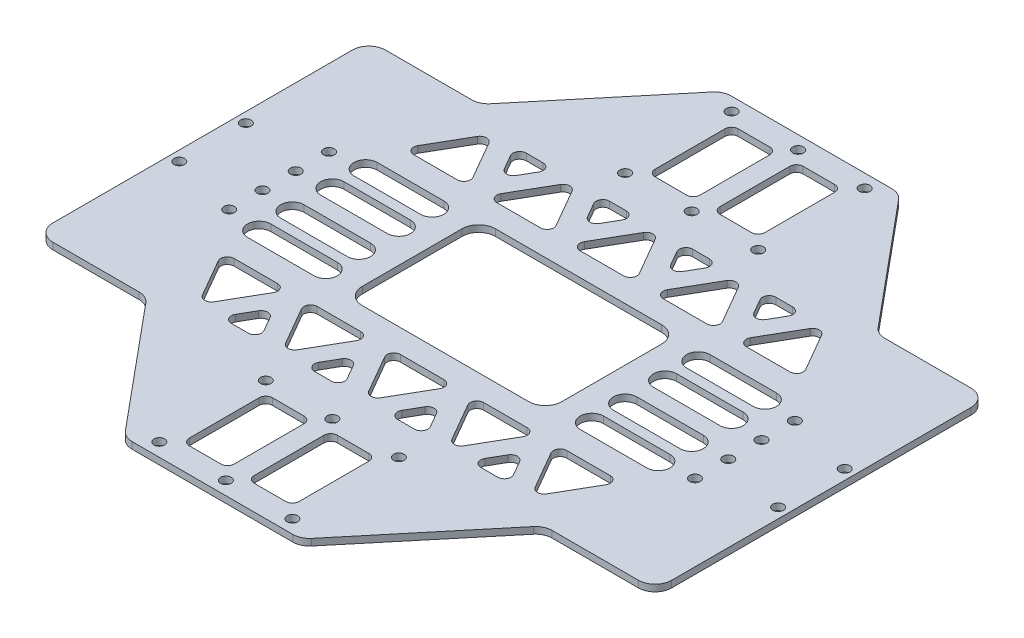
from build123d import *

# Parameters (mm, degrees)
SKETCH_1_W          = 186
SKETCH_1_H          = 100
SKETCH_1_R          = 1.6
EXTRUDE_1_DEPTH     = 2
SKETCH_2_W          = 53
SKETCH_2_H          = 40
SKETCH_2_R          = 1.6
EXTRUDE_2_DEPTH     = 2
SKETCH_3_R          = 1.6
CUT_EXTRUDE_1_DEPTH = 3
EXTRUDE_3_DEPTH     = 2
SKETCH_5_W          = 13.5
SKETCH_5_H          = 25
SKETCH_5_W_2        = 60
SKETCH_5_H_2        = 40
CUT_EXTRUDE_2_DEPTH = 3
FILLET_1_R          = 2
FILLET_2_R          = 5


with BuildPart() as part:
    # 草图1 → 凸台-拉伸1 (new body)
    with BuildSketch(Plane(origin=(0, 0, 0), x_dir=(1, 0, 0), z_dir=(0, 1, 0))):
        Rectangle(SKETCH_1_W, SKETCH_1_H)
        with Locations((-90, 10)):
            Circle(SKETCH_1_R, mode=Mode.SUBTRACT)
        with Locations((-90, -10)):
            Circle(SKETCH_1_R, mode=Mode.SUBTRACT)
        with Locations((90, -10)):
            Circle(SKETCH_1_R, mode=Mode.SUBTRACT)
        with Locations((90, 10)):
            Circle(SKETCH_1_R, mode=Mode.SUBTRACT)
    extrude(amount=EXTRUDE_1_DEPTH)

    # 草图2 → 凸台-拉伸2 (add)
    with BuildSketch(Plane.XZ):
        with Locations((0, 70)):
            Rectangle(SKETCH_2_W, SKETCH_2_H)
        with Locations((-20, 86)):
            Circle(SKETCH_2_R, mode=Mode.SUBTRACT)
        with Locations((0, 86)):
            Circle(SKETCH_2_R, mode=Mode.SUBTRACT)
        with Locations((20, 86)):
            Circle(SKETCH_2_R, mode=Mode.SUBTRACT)
        with Locations((20, 54)):
            Circle(SKETCH_2_R, mode=Mode.SUBTRACT)
        with Locations((0, 54)):
            Circle(SKETCH_2_R, mode=Mode.SUBTRACT)
        with Locations((-20, 54)):
            Circle(SKETCH_2_R, mode=Mode.SUBTRACT)
        with Locations((0, -70)):
            Rectangle(SKETCH_2_W, SKETCH_2_H)
        with Locations((-20, -54)):
            Circle(SKETCH_2_R, mode=Mode.SUBTRACT)
        with Locations((0, -54)):
            Circle(SKETCH_2_R, mode=Mode.SUBTRACT)
        with Locations((20, -54)):
            Circle(SKETCH_2_R, mode=Mode.SUBTRACT)
        with Locations((20, -86)):
            Circle(SKETCH_2_R, mode=Mode.SUBTRACT)
        with Locations((0, -86)):
            Circle(SKETCH_2_R, mode=Mode.SUBTRACT)
        with Locations((-20, -86)):
            Circle(SKETCH_2_R, mode=Mode.SUBTRACT)
    extrude(amount=-EXTRUDE_2_DEPTH)

    # 草图3 → 切除-拉伸1 (cut, through all)
    with BuildSketch(Plane(origin=(0, 2, 0), x_dir=(1, 0, 0), z_dir=(0, 1, 0))):
        with Locations((-70, -15)):
            Circle(SKETCH_3_R)
        with Locations((-70, -5)):
            Circle(SKETCH_3_R)
        with Locations((-70, 5)):
            Circle(SKETCH_3_R)
        with Locations((-70, 15)):
            Circle(SKETCH_3_R)
        with Locations((70, 15)):
            Circle(SKETCH_3_R)
        with Locations((70, 5)):
            Circle(SKETCH_3_R)
        with Locations((70, -5)):
            Circle(SKETCH_3_R)
        with Locations((70, -15)):
            Circle(SKETCH_3_R)
    extrude(amount=-CUT_EXTRUDE_1_DEPTH, mode=Mode.SUBTRACT)

    # 草图4 → 凸台-拉伸3 (add)
    with BuildSketch(Plane(origin=(0, 2, 0), x_dir=(1, 0, 0), z_dir=(0, 1, 0))):
        Polygon((-26.5, 90), (-59.75, 50), (-26.5, 50), align=None)
        Polygon((59.75, 50), (26.5, 50), (26.5, 90), align=None)
        Polygon((26.5, -90), (59.75, -50), (26.5, -50), align=None)
        Polygon((-59.75, -50), (-26.5, -50), (-26.5, -90), align=None)
    extrude(amount=-EXTRUDE_3_DEPTH)

    # 草图5 → 切除-拉伸2 (cut, through all)
    with BuildSketch(Plane.XZ):
        with Locations((9.75, 70)):
            Rectangle(SKETCH_5_W, SKETCH_5_H)
        with Locations((-9.75, 70)):
            Rectangle(SKETCH_5_W, SKETCH_5_H)
        with Locations((9.75, -70)):
            Rectangle(SKETCH_5_W, SKETCH_5_H)
        with Locations((-9.75, -70)):
            Rectangle(SKETCH_5_W, SKETCH_5_H)
        with BuildLine():
            Line((-60, -2.5), (-40, -2.5))
            ThreePointArc((-40, -2.5), (-36.5, -6), (-40, -9.5))
            Line((-40, -9.5), (-60, -9.5))
            ThreePointArc((-60, -9.5), (-63.5, -6), (-60, -2.5))
        make_face()
        Rectangle(SKETCH_5_W_2, SKETCH_5_H_2)
        with BuildLine():
            Line((-60, -19.5), (-40, -19.5))
            ThreePointArc((-40, -19.5), (-36.5, -16), (-40, -12.5))
            Line((-40, -12.5), (-60, -12.5))
            ThreePointArc((-60, -12.5), (-63.5, -16), (-60, -19.5))
        make_face()
        with BuildLine():
            Line((-60, 12.5), (-40, 12.5))
            ThreePointArc((-40, 12.5), (-36.5, 16), (-40, 19.5))
            Line((-40, 19.5), (-60, 19.5))
            ThreePointArc((-60, 19.5), (-63.5, 16), (-60, 12.5))
        make_face()
        with BuildLine():
            Line((-60, 2.5), (-40, 2.5))
            ThreePointArc((-40, 2.5), (-36.5, 6), (-40, 9.5))
            Line((-40, 9.5), (-60, 9.5))
            ThreePointArc((-60, 9.5), (-63.5, 6), (-60, 2.5))
        make_face()
        with BuildLine():
            Line((60, 2.5), (40, 2.5))
            ThreePointArc((40, 2.5), (36.5, 6), (40, 9.5))
            Line((40, 9.5), (60, 9.5))
            ThreePointArc((60, 9.5), (63.5, 6), (60, 2.5))
        make_face()
        with BuildLine():
            Line((60, 12.5), (40, 12.5))
            ThreePointArc((40, 12.5), (36.5, 16), (40, 19.5))
            Line((40, 19.5), (60, 19.5))
            ThreePointArc((60, 19.5), (63.5, 16), (60, 12.5))
        make_face()
        with BuildLine():
            Line((60, -12.5), (40, -12.5))
            ThreePointArc((40, -12.5), (36.5, -16), (40, -19.5))
            Line((40, -19.5), (60, -19.5))
            ThreePointArc((60, -19.5), (63.5, -16), (60, -12.5))
        make_face()
        with BuildLine():
            Line((60, -2.5), (40, -2.5))
            ThreePointArc((40, -2.5), (36.5, -6), (40, -9.5))
            Line((40, -9.5), (60, -9.5))
            ThreePointArc((60, -9.5), (63.5, -6), (60, -2.5))
        make_face()
        Polygon((-50, 44.320508076), (-60, 27), (-40, 27), align=None)
        Polygon((-15, 27), (-25, 44.320508076), (-35, 27), align=None)
        Polygon((10, 27), (0, 44.320508076), (-10, 27), align=None)
        Polygon((35, 27), (25, 44.320508076), (15, 27), align=None)
        Polygon((60, 27), (50, 44.320508076), (40, 27), align=None)
        Polygon((-43.5, 44.320508076), (-31.5, 44.320508076), (-37.5, 33.92820323), align=None)
        Polygon((-12.5, 33.92820323), (-18.5, 44.320508076), (-6.5, 44.320508076), align=None)
        Polygon((12.5, 33.92820323), (6.5, 44.320508076), (18.5, 44.320508076), align=None)
        Polygon((37.5, 33.92820323), (31.5, 44.320508076), (43.5, 44.320508076), align=None)
        Polygon((43.5, -44.320508076), (37.5, -33.92820323), (31.5, -44.320508076), align=None)
        Polygon((18.5, -44.320508076), (12.5, -33.92820323), (6.5, -44.320508076), align=None)
        Polygon((-6.5, -44.320508076), (-12.5, -33.92820323), (-18.5, -44.320508076), align=None)
        Polygon((-37.5, -33.92820323), (-43.5, -44.320508076), (-31.5, -44.320508076), align=None)
        Polygon((40, -27), (60, -27), (50, -44.320508076), align=None)
        Polygon((15, -27), (35, -27), (25, -44.320508076), align=None)
        Polygon((-10, -27), (10, -27), (0, -44.320508076), align=None)
        Polygon((-35, -27), (-15, -27), (-25, -44.320508076), align=None)
        Polygon((-40, -27), (-50, -44.320508076), (-60, -27), align=None)
    extrude(amount=-CUT_EXTRUDE_2_DEPTH, mode=Mode.SUBTRACT)

    # 圆角1
    fillet_1_edges = [part.edges().sort_by_distance(p)[0] for p in [
        (-37.5, 1, 33.92820323),
        (-43.5, 1, 44.320508076),
        (-31.5, 1, 44.320508076),
        (-50, 1, 44.320508076),
        (-40, 1, 27),
        (-60, 1, 27),
        (-35, 1, 27),
        (-25, 1, 44.320508076),
        (-15, 1, 27),
        (-10, 1, 27),
        (0, 1, 44.320508076),
        (10, 1, 27),
        (16.5, 1, 82.5),
        (16.5, 1, 57.5),
        (3, 1, 57.5),
        (3, 1, 82.5),
        (16.5, 1, -82.5),
        (3, 1, -82.5),
        (3, 1, -57.5),
        (16.5, 1, -57.5),
        (-16.5, 1, -82.5),
        (-16.5, 1, -57.5),
        (-3, 1, -57.5),
        (-3, 1, -82.5),
        (50, 1, -44.320508076),
        (40, 1, -27),
        (60, 1, -27),
        (18.5, 1, -44.320508076),
        (6.5, 1, -44.320508076),
        (12.5, 1, -33.92820323),
        (43.5, 1, -44.320508076),
        (31.5, 1, -44.320508076),
        (37.5, 1, -33.92820323),
        (-15, 1, -27),
        (-25, 1, -44.320508076),
        (-35, 1, -27),
        (25, 1, -44.320508076),
        (15, 1, -27),
        (35, 1, -27),
        (0, 1, -44.320508076),
        (-10, 1, -27),
        (10, 1, -27),
        (6.5, 1, 44.320508076),
        (18.5, 1, 44.320508076),
        (12.5, 1, 33.92820323),
        (-18.5, 1, 44.320508076),
        (-6.5, 1, 44.320508076),
        (-12.5, 1, 33.92820323),
        (40, 1, 27),
        (50, 1, 44.320508076),
        (60, 1, 27),
        (15, 1, 27),
        (25, 1, 44.320508076),
        (35, 1, 27),
        (-50, 1, -44.320508076),
        (-60, 1, -27),
        (-40, 1, -27),
        (-18.5, 1, -44.320508076),
        (-12.5, 1, -33.92820323),
        (-6.5, 1, -44.320508076),
        (-37.5, 1, -33.92820323),
        (-31.5, 1, -44.320508076),
        (-43.5, 1, -44.320508076),
        (31.5, 1, 44.320508076),
        (43.5, 1, 44.320508076),
        (37.5, 1, 33.92820323),
        (-16.5, 1, 57.5),
        (-16.5, 1, 82.5),
        (-3, 1, 82.5),
        (-3, 1, 57.5),
    ]]
    fillet(fillet_1_edges, radius=FILLET_1_R)

    # 圆角2
    fillet_2_edges = [part.edges().sort_by_distance(p)[0] for p in [
        (-59.75, 1, -50),
        (59.75, 1, -50),
        (59.75, 1, 50),
        (-59.75, 1, 50),
        (-26.5, 1, 90),
        (26.5, 1, 90),
        (30, 1, 20),
        (30, 1, -20),
        (-30, 1, -20),
        (-30, 1, 20),
        (-26.5, 1, -90),
        (26.5, 1, -90),
        (93, 1, 50),
        (-93, 1, 50),
        (-93, 1, -50),
        (93, 1, -50),
    ]]
    fillet(fillet_2_edges, radius=FILLET_2_R)


solid = part.part
